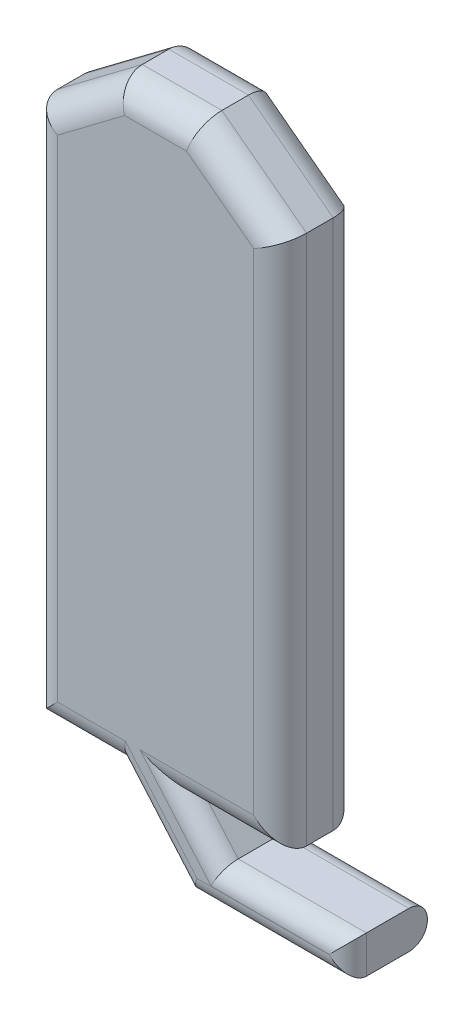
from build123d import *

# Parameters (mm, degrees)
BOSS_EXTRUDE1_DEPTH = 0.762
FILLET6_R           = 0.254
FILLET7_R           = 0.1778


with BuildPart() as part:
    # Sketch1 → Boss-Extrude1 (new body)
    with BuildSketch(Plane.XY):
        Polygon((-10.633992105, 13.234648789), (-10.633992105, 18.314648789), (-9.822578427, 18.926092853), (-9.060578427, 18.926092853), (-8.249164748, 18.314648789), (-8.249164748, 13.234648789), (-9.138164748, 13.234648789), (-8.828298732, 12.875241629), (-7.601260072, 12.875241629), (-7.601260072, 12.515834468), (-9.125260072, 12.515834468), (-9.744992105, 13.234648789), align=None)
    extrude(amount=BOSS_EXTRUDE1_DEPTH)

    # Fillet6
    fillet6_edges = [part.edges().sort_by_distance(p)[0] for p in [
        (-8.693664748, 13.234648789, 0.762),
        (-10.189492105, 13.234648789, 0),
        (-10.633992105, 15.774648789, 0),
        (-10.228285266, 18.620370821, 0),
        (-9.441578427, 18.926092853, 0),
        (-8.654871588, 18.620370821, 0),
        (-8.249164748, 15.774648789, 0),
        (-8.693664748, 13.234648789, 0),
        (-8.249164748, 15.774648789, 0.762),
        (-8.654871588, 18.620370821, 0.762),
        (-9.441578427, 18.926092853, 0.762),
        (-10.228285266, 18.620370821, 0.762),
        (-10.633992105, 15.774648789, 0.762),
        (-10.189492105, 13.234648789, 0.762),
    ]]
    fillet(fillet6_edges, radius=FILLET6_R)

    # Fillet7
    fillet7_edges = [part.edges().sort_by_distance(p)[0] for p in [
        (-8.363260072, 12.515834468, 0),
        (-9.435126088, 12.875241629, 0),
        (-8.98323174, 13.054945209, 0),
        (-8.214779402, 12.875241629, 0),
        (-7.601260072, 12.695538049, 0.762),
        (-8.363260072, 12.515834468, 0.762),
        (-9.435126088, 12.875241629, 0.762),
        (-8.214779402, 12.875241629, 0.762),
        (-8.98323174, 13.054945209, 0.762),
    ]]
    fillet(fillet7_edges, radius=FILLET7_R)


solid = part.part
